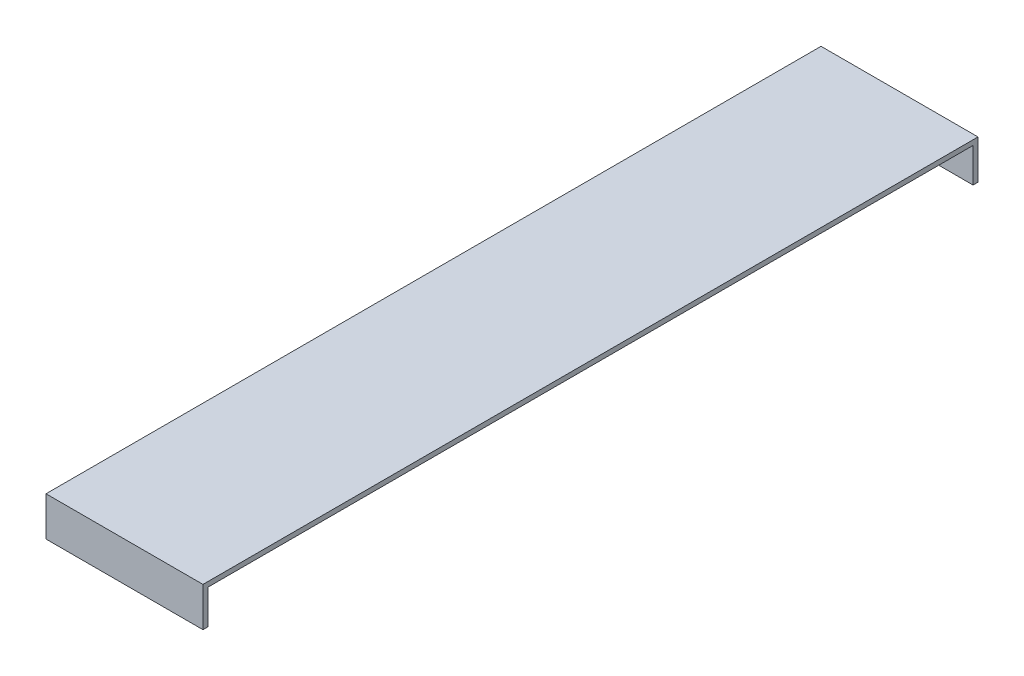
from build123d import *

# Parameters (mm, degrees)
BOSS_EXTRUDE1_DEPTH = 101.6


with BuildPart() as part:
    # Sketch1 → Boss-Extrude1 (new body)
    with BuildSketch(Plane(origin=(0, 0, 0), x_dir=(0, 0, -1), z_dir=(1, 0, 0))):
        Polygon((0, 0), (501.65, 0), (501.65, -25.4), (498.475, -25.4), (498.475, -3.175), (3.175, -3.175), (3.175, -25.4), (0, -25.4), align=None)
    extrude(amount=BOSS_EXTRUDE1_DEPTH)


solid = part.part
